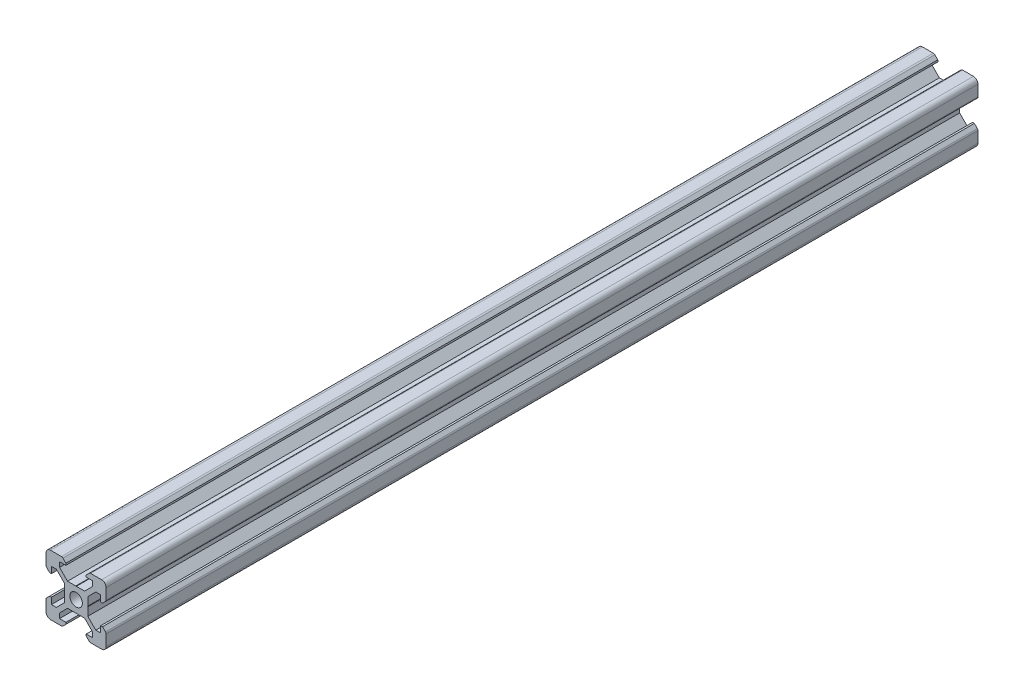
from build123d import *

# Parameters (mm, degrees)
SKETCH1_R           = 2.1
BOSS_EXTRUDE1_DEPTH = 290


with BuildPart() as part:
    # Sketch1 → Boss-Extrude1 (new body)
    with BuildSketch(Plane.XY):
        with BuildLine():
            Line((-8.5, 10), (-4.862792737, 10))
            ThreePointArc((-4.862792737, 10), (-4.598292737, 9.947387679), (-4.374060464, 9.797560464))
            Line((-4.374060464, 9.797560464), (-3.3865, 8.81))
            Line((-3.3865, 8.81), (-3.3865, 8.2))
            Line((-3.3865, 8.2), (-5.5, 8.2))
            Line((-5.5, 8.2), (-5.5, 6.561))
            Line((-5.5, 6.561), (-2.8395, 3.9005))
            Line((-2.8395, 3.9005), (-0.1, 3.9005))
            Line((-0.1, 3.9005), (0, 3.8005))
            Line((0, 3.8005), (0.1, 3.9005))
            Line((0.1, 3.9005), (2.8395, 3.9005))
            Line((2.8395, 3.9005), (5.5, 6.561))
            Line((5.5, 6.561), (5.5, 8.2))
            Line((5.5, 8.2), (3.3865, 8.2))
            Line((3.3865, 8.2), (3.3865, 8.81))
            Line((3.3865, 8.81), (4.374060464, 9.797560464))
            ThreePointArc((4.374060464, 9.797560464), (4.598292737, 9.947387679), (4.862792737, 10))
            Line((4.862792737, 10), (8.5, 10))
            ThreePointArc((8.5, 10), (9.560660172, 9.560660172), (10, 8.5))
            Line((10, 8.5), (10, 4.862792737))
            ThreePointArc((10, 4.862792737), (9.947387679, 4.598292737), (9.797560464, 4.374060464))
            Line((9.797560464, 4.374060464), (8.81, 3.3865))
            Line((8.81, 3.3865), (8.2, 3.3865))
            Line((8.2, 3.3865), (8.2, 5.5))
            Line((8.2, 5.5), (6.561, 5.5))
            Line((6.561, 5.5), (3.9005, 2.8395))
            Line((3.9005, 2.8395), (3.9005, 0.1))
            Line((3.9005, 0.1), (3.8005, 0))
            Line((3.8005, 0), (3.9005, -0.1))
            Line((3.9005, -0.1), (3.9005, -2.8395))
            Line((3.9005, -2.8395), (6.561, -5.5))
            Line((6.561, -5.5), (8.2, -5.5))
            Line((8.2, -5.5), (8.2, -3.3865))
            Line((8.2, -3.3865), (8.81, -3.3865))
            Line((8.81, -3.3865), (9.797560464, -4.374060464))
            ThreePointArc((9.797560464, -4.374060464), (9.947387679, -4.598292737), (10, -4.862792737))
            Line((10, -4.862792737), (10, -8.5))
            ThreePointArc((10, -8.5), (9.560660172, -9.560660172), (8.5, -10))
            Line((8.5, -10), (4.862792737, -10))
            ThreePointArc((4.862792737, -10), (4.598292737, -9.947387679), (4.374060464, -9.797560464))
            Line((4.374060464, -9.797560464), (3.3865, -8.81))
            Line((3.3865, -8.81), (3.3865, -8.2))
            Line((3.3865, -8.2), (5.5, -8.2))
            Line((5.5, -8.2), (5.5, -6.561))
            Line((5.5, -6.561), (2.8395, -3.9005))
            Line((2.8395, -3.9005), (0.1, -3.9005))
            Line((0.1, -3.9005), (0, -3.8005))
            Line((0, -3.8005), (-0.1, -3.9005))
            Line((-0.1, -3.9005), (-2.8395, -3.9005))
            Line((-2.8395, -3.9005), (-5.5, -6.561))
            Line((-5.5, -6.561), (-5.5, -8.2))
            Line((-5.5, -8.2), (-3.3865, -8.2))
            Line((-3.3865, -8.2), (-3.3865, -8.81))
            Line((-3.3865, -8.81), (-4.374060464, -9.797560464))
            ThreePointArc((-4.374060464, -9.797560464), (-4.598292737, -9.947387679), (-4.862792737, -10))
            Line((-4.862792737, -10), (-8.5, -10))
            ThreePointArc((-8.5, -10), (-9.560660172, -9.560660172), (-10, -8.5))
            Line((-10, -8.5), (-10, -4.862792737))
            ThreePointArc((-10, -4.862792737), (-9.947387679, -4.598292737), (-9.797560464, -4.374060464))
            Line((-9.797560464, -4.374060464), (-8.81, -3.3865))
            Line((-8.81, -3.3865), (-8.2, -3.3865))
            Line((-8.2, -3.3865), (-8.2, -5.5))
            Line((-8.2, -5.5), (-6.561, -5.5))
            Line((-6.561, -5.5), (-3.9005, -2.8395))
            Line((-3.9005, -2.8395), (-3.9005, -0.1))
            Line((-3.9005, -0.1), (-3.8005, 0))
            Line((-3.8005, 0), (-3.9005, 0.1))
            Line((-3.9005, 0.1), (-3.9005, 2.8395))
            Line((-3.9005, 2.8395), (-6.561, 5.5))
            Line((-6.561, 5.5), (-8.2, 5.5))
            Line((-8.2, 5.5), (-8.2, 3.3865))
            Line((-8.2, 3.3865), (-8.81, 3.3865))
            Line((-8.81, 3.3865), (-9.797560464, 4.374060464))
            ThreePointArc((-9.797560464, 4.374060464), (-9.947387679, 4.598292737), (-10, 4.862792737))
            Line((-10, 4.862792737), (-10, 8.5))
            ThreePointArc((-10, 8.5), (-9.560660172, 9.560660172), (-8.5, 10))
        make_face()
        Circle(SKETCH1_R, mode=Mode.SUBTRACT)
    extrude(amount=BOSS_EXTRUDE1_DEPTH)


solid = part.part
